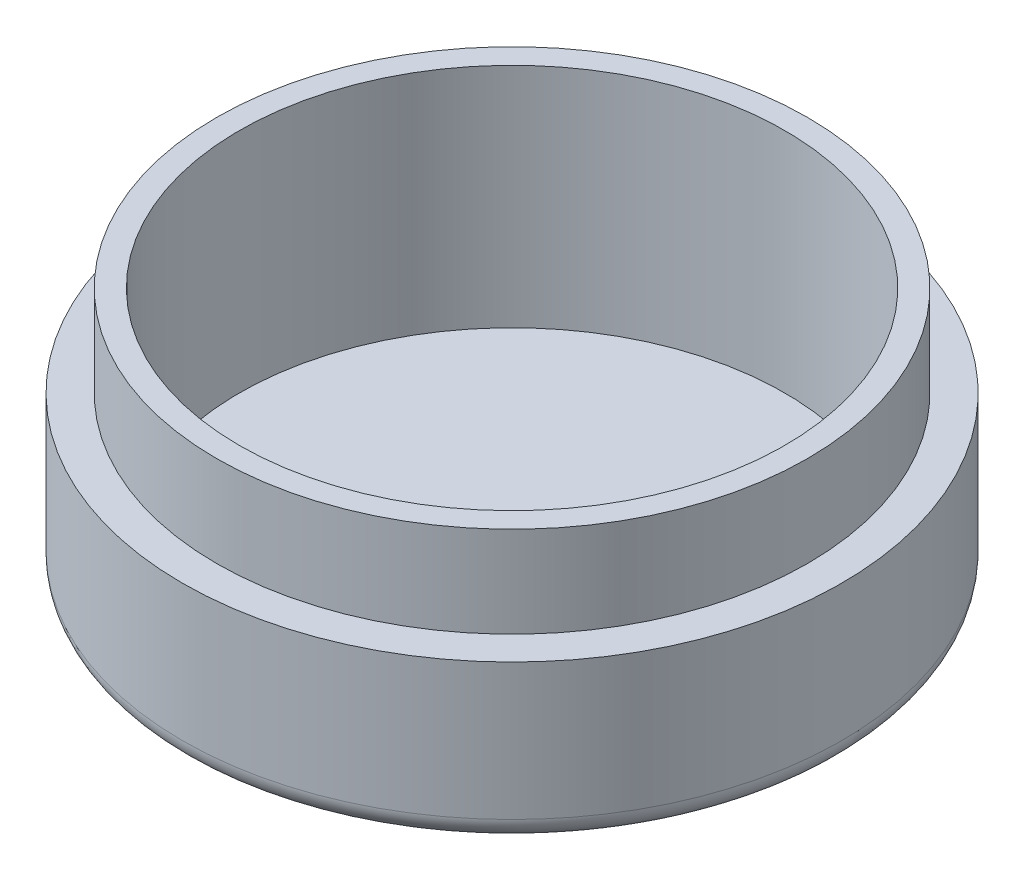
from build123d import *

# Parameters (mm, degrees)
SKETCH1_R           = 14.5
BOSS_EXTRUDE1_DEPTH = 1
SKETCH2_R           = 14.5
SKETCH2_R_2         = 12
BOSS_EXTRUDE2_DEPTH = 6
SKETCH3_R           = 13
SKETCH3_R_2         = 12
BOSS_EXTRUDE3_DEPTH = 4
FILLET1_R           = 1


with BuildPart() as part:
    # Sketch1 → Boss-Extrude1 (new body)
    with BuildSketch(Plane(origin=(0, 0, 0), x_dir=(1, 0, 0), z_dir=(0, 1, 0))):
        Circle(SKETCH1_R)
    extrude(amount=BOSS_EXTRUDE1_DEPTH)

    # Sketch2 → Boss-Extrude2 (add)
    with BuildSketch(Plane(origin=(0, 1, 0), x_dir=(1, 0, 0), z_dir=(0, 1, 0))):
        Circle(SKETCH2_R)
        Circle(SKETCH2_R_2, mode=Mode.SUBTRACT)
    extrude(amount=BOSS_EXTRUDE2_DEPTH)

    # Sketch3 → Boss-Extrude3 (add)
    with BuildSketch(Plane(origin=(0, 7, 0), x_dir=(1, 0, 0), z_dir=(0, 1, 0))):
        Circle(SKETCH3_R)
        Circle(SKETCH3_R_2, mode=Mode.SUBTRACT)
    extrude(amount=BOSS_EXTRUDE3_DEPTH)

    # Fillet1
    fillet1_edges = [part.edges().sort_by_distance(p)[0] for p in [
        (-14.5, 0, 0),
    ]]
    fillet(fillet1_edges, radius=FILLET1_R)


solid = part.part
